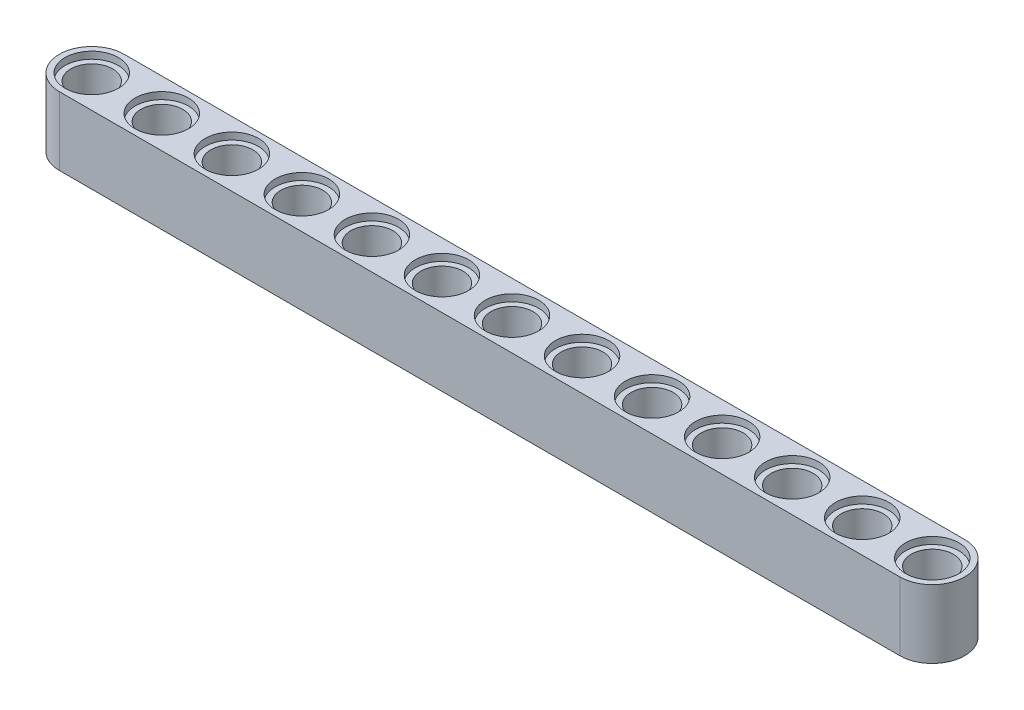
from build123d import *

# Parameters (mm, degrees)
BOSS_EXTRUDE3_DEPTH = 7.8
SKETCH2_R           = 2.4
CUT_EXTRUDE4_DEPTH  = 7.8
SKETCH3_R           = 3.05
CUT_EXTRUDE5_DEPTH  = 0.8
SKETCH4_R           = 3.05
CUT_EXTRUDE6_DEPTH  = 0.8


with BuildPart() as part:
    # Sketch1 → Boss-Extrude3 (new body)
    with BuildSketch(Plane(origin=(0, 0, 0), x_dir=(1, 0, 0), z_dir=(0, 1, 0))):
        with BuildLine():
            Line((-16, -3.7), (80, -3.7))
            ThreePointArc((80, -3.7), (83.7, 0), (80, 3.7))
            Line((80, 3.7), (-16, 3.7))
            ThreePointArc((-16, 3.7), (-19.7, 0), (-16, -3.7))
        make_face()
    extrude(amount=BOSS_EXTRUDE3_DEPTH)

    # Sketch2 → Cut-Extrude4 (cut)
    with BuildSketch(Plane(origin=(0, 7.8, 0), x_dir=(1, 0, 0), z_dir=(0, 1, 0))):
        Circle(SKETCH2_R)
        with Locations((8, 0)):
            Circle(SKETCH2_R)
        with Locations((16, 0)):
            Circle(SKETCH2_R)
        with Locations((-16, 0)):
            Circle(SKETCH2_R)
        with Locations((-8, 0)):
            Circle(SKETCH2_R)
        with Locations((24, 0)):
            Circle(SKETCH2_R)
        with Locations((32, 0)):
            Circle(SKETCH2_R)
        with Locations((40, 0)):
            Circle(SKETCH2_R)
        with Locations((48, 0)):
            Circle(SKETCH2_R)
        with Locations((56, 0)):
            Circle(SKETCH2_R)
        with Locations((64, 0)):
            Circle(SKETCH2_R)
        with Locations((72, 0)):
            Circle(SKETCH2_R)
        with Locations((80, 0)):
            Circle(SKETCH2_R)
    extrude(amount=-CUT_EXTRUDE4_DEPTH, mode=Mode.SUBTRACT)

    # Sketch3 → Cut-Extrude5 (cut)
    with BuildSketch(Plane(origin=(0, 7.8, 0), x_dir=(1, 0, 0), z_dir=(0, 1, 0))):
        Circle(SKETCH3_R)
        with Locations((8, 0)):
            Circle(SKETCH3_R)
        with Locations((16, 0)):
            Circle(SKETCH3_R)
        with Locations((-16, 0)):
            Circle(SKETCH3_R)
        with Locations((-8, 0)):
            Circle(SKETCH3_R)
        with Locations((32, 0)):
            Circle(SKETCH3_R)
        with Locations((24, 0)):
            Circle(SKETCH3_R)
        with Locations((40, 0)):
            Circle(SKETCH3_R)
        with Locations((48, 0)):
            Circle(SKETCH3_R)
        with Locations((56, 0)):
            Circle(SKETCH3_R)
        with Locations((64, 0)):
            Circle(SKETCH3_R)
        with Locations((72, 0)):
            Circle(SKETCH3_R)
        with Locations((80, 0)):
            Circle(SKETCH3_R)
    extrude(amount=-CUT_EXTRUDE5_DEPTH, mode=Mode.SUBTRACT)

    # Sketch4 → Cut-Extrude6 (cut)
    with BuildSketch(Plane.XZ):
        Circle(SKETCH4_R)
        with Locations((8, 0)):
            Circle(SKETCH4_R)
        with Locations((16, 0)):
            Circle(SKETCH4_R)
        with Locations((-16, 0)):
            Circle(SKETCH4_R)
        with Locations((-8, 0)):
            Circle(SKETCH4_R)
        with Locations((32, 0)):
            Circle(SKETCH4_R)
        with Locations((24, 0)):
            Circle(SKETCH4_R)
        with Locations((40, 0)):
            Circle(SKETCH4_R)
        with Locations((48, 0)):
            Circle(SKETCH4_R)
        with Locations((56, 0)):
            Circle(SKETCH4_R)
        with Locations((64, 0)):
            Circle(SKETCH4_R)
        with Locations((72, 0)):
            Circle(SKETCH4_R)
        with Locations((80, 0)):
            Circle(SKETCH4_R)
    extrude(amount=-CUT_EXTRUDE6_DEPTH, mode=Mode.SUBTRACT)


solid = part.part
